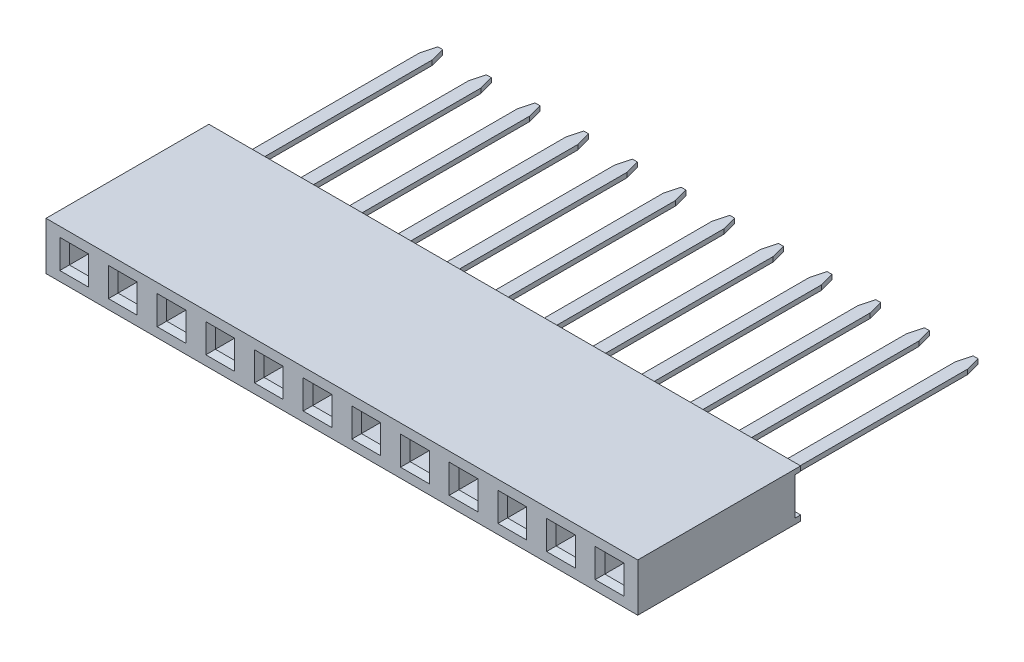
from build123d import *

# Parameters (mm, degrees)
SKETCH1_W                  = 30.88
SKETCH1_H                  = 2.5
BOSS_EXTRUDE1_DEPTH        = 8.5
SKETCH2_W                  = 1
SKETCH2_H                  = 1
CUT_EXTRUDE1_DEPTH         = 2.25
CHAMFER1_SIZE              = 0.25
SKETCH3_W                  = 0.3
SKETCH3_H                  = 1.963850618
CUT_EXTRUDE2_DEPTH         = 31.88
SKETCH4_W                  = 0.65
SKETCH4_H                  = 10.9
BOSS_EXTRUDE2_DEPTH        = 0.125
CHAMFER2_SIZE              = 0.2
CHAMFER2_SIZE2             = 0.746410162
LPATTERN4_COUNT            = 12
LPATTERN4_PITCH            = 2.54
LPATTERN5_COUNT            = 12
LPATTERN5_PITCH            = 2.54
CHAMFER1_OF_LPATTERN5_SIZE = 0.25


with BuildPart() as part:
    # Sketch1 → Boss-Extrude1 (new body)
    with BuildSketch(Plane.XY):
        with Locations((15.44, 1.25)):
            Rectangle(SKETCH1_W, SKETCH1_H)
    extrude(amount=BOSS_EXTRUDE1_DEPTH)

    # Sketch2 → Cut-Extrude1 (cut)
    with BuildSketch(Plane.XY.offset(8.5)):
        with Locations((1.47, 1.25)):
            Rectangle(SKETCH2_W, SKETCH2_H)
    cut_extrude1 = extrude(amount=-CUT_EXTRUDE1_DEPTH, mode=Mode.SUBTRACT)

    # Chamfer1
    chamfer1_edges = [part.edges().sort_by_distance(p)[0] for p in [
        (0.97, 1.25, 8.5),
        (1.47, 0.75, 8.5),
        (1.97, 1.25, 8.5),
        (1.47, 1.75, 8.5),
    ]]
    chamfer(chamfer1_edges, length=CHAMFER1_SIZE)

    # Sketch3 → Cut-Extrude2 (cut, through all)
    with BuildSketch(Plane.ZY):
        with Locations((0.15, 1.268074691)):
            Rectangle(SKETCH3_W, SKETCH3_H)
    extrude(amount=-CUT_EXTRUDE2_DEPTH, mode=Mode.SUBTRACT)

    # LPattern5: Cut-Extrude1 ×12
    with Locations(*[(i * LPATTERN5_PITCH, 0, 0) for i in range(1, LPATTERN5_COUNT)]):
        add(cut_extrude1, mode=Mode.SUBTRACT)

    # Chamfer1 of LPattern5
    chamfer1_of_lpattern5_edges = [part.edges().sort_by_distance(p)[0] for p in [
        (3.51, 1.25, 8.5),
        (4.01, 0.75, 8.5),
        (4.51, 1.25, 8.5),
        (4.01, 1.75, 8.5),
        (6.05, 1.25, 8.5),
        (6.55, 0.75, 8.5),
        (7.05, 1.25, 8.5),
        (6.55, 1.75, 8.5),
        (8.59, 1.25, 8.5),
        (9.09, 0.75, 8.5),
        (9.59, 1.25, 8.5),
        (9.09, 1.75, 8.5),
        (11.13, 1.25, 8.5),
        (11.63, 0.75, 8.5),
        (12.13, 1.25, 8.5),
        (11.63, 1.75, 8.5),
        (13.67, 1.25, 8.5),
        (14.17, 0.75, 8.5),
        (14.67, 1.25, 8.5),
        (14.17, 1.75, 8.5),
        (16.21, 1.25, 8.5),
        (16.71, 0.75, 8.5),
        (17.21, 1.25, 8.5),
        (16.71, 1.75, 8.5),
        (18.75, 1.25, 8.5),
        (19.25, 0.75, 8.5),
        (19.75, 1.25, 8.5),
        (19.25, 1.75, 8.5),
        (21.29, 1.25, 8.5),
        (21.79, 0.75, 8.5),
        (22.29, 1.25, 8.5),
        (21.79, 1.75, 8.5),
        (23.83, 1.25, 8.5),
        (24.33, 0.75, 8.5),
        (24.83, 1.25, 8.5),
        (24.33, 1.75, 8.5),
        (26.37, 1.25, 8.5),
        (26.87, 0.75, 8.5),
        (27.37, 1.25, 8.5),
        (26.87, 1.75, 8.5),
        (28.91, 1.25, 8.5),
        (29.41, 0.75, 8.5),
        (29.91, 1.25, 8.5),
        (29.41, 1.75, 8.5),
    ]]
    chamfer(chamfer1_of_lpattern5_edges, length=CHAMFER1_OF_LPATTERN5_SIZE)


with BuildPart() as body_2:
    # Sketch4 → Boss-Extrude2 (new body, symmetric)
    with BuildSketch(Plane(origin=(0, 1.25, 0), x_dir=(-1, 0, 0), z_dir=(0, -1, 0))):
        with Locations((-1.47, 5.15)):
            Rectangle(SKETCH4_W, SKETCH4_H)
    extrude(amount=BOSS_EXTRUDE2_DEPTH, both=True)

    # Chamfer2
    chamfer2_edges = [body_2.edges().sort_by_distance(p)[0] for p in [
        (1.795, 1.25, -10.6),
        (1.145, 1.25, -10.6),
    ]]
    chamfer2_side = [body_2.faces().sort_by_distance(p)[0] for p in [
        (1.47, 1.25, -10.6),
    ]]
    chamfer(chamfer2_edges, length=CHAMFER2_SIZE, length2=CHAMFER2_SIZE2, reference=chamfer2_side[0])


with BuildPart() as lpattern4_1:
    # LPattern4: pattern copy
    add(body_2.part.moved(Location(Vector(1, 0, 0) * (1 * LPATTERN4_PITCH))))


with BuildPart() as lpattern4_2:
    # LPattern4: pattern copy
    add(body_2.part.moved(Location(Vector(1, 0, 0) * (2 * LPATTERN4_PITCH))))


with BuildPart() as lpattern4_3:
    # LPattern4: pattern copy
    add(body_2.part.moved(Location(Vector(1, 0, 0) * (3 * LPATTERN4_PITCH))))


with BuildPart() as lpattern4_4:
    # LPattern4: pattern copy
    add(body_2.part.moved(Location(Vector(1, 0, 0) * (4 * LPATTERN4_PITCH))))


with BuildPart() as lpattern4_5:
    # LPattern4: pattern copy
    add(body_2.part.moved(Location(Vector(1, 0, 0) * (5 * LPATTERN4_PITCH))))


with BuildPart() as lpattern4_6:
    # LPattern4: pattern copy
    add(body_2.part.moved(Location(Vector(1, 0, 0) * (6 * LPATTERN4_PITCH))))


with BuildPart() as lpattern4_7:
    # LPattern4: pattern copy
    add(body_2.part.moved(Location(Vector(1, 0, 0) * (7 * LPATTERN4_PITCH))))


with BuildPart() as lpattern4_8:
    # LPattern4: pattern copy
    add(body_2.part.moved(Location(Vector(1, 0, 0) * (8 * LPATTERN4_PITCH))))


with BuildPart() as lpattern4_9:
    # LPattern4: pattern copy
    add(body_2.part.moved(Location(Vector(1, 0, 0) * (9 * LPATTERN4_PITCH))))


with BuildPart() as lpattern4_10:
    # LPattern4: pattern copy
    add(body_2.part.moved(Location(Vector(1, 0, 0) * (10 * LPATTERN4_PITCH))))


with BuildPart() as lpattern4_11:
    # LPattern4: pattern copy
    add(body_2.part.moved(Location(Vector(1, 0, 0) * (11 * LPATTERN4_PITCH))))


solid = Compound([part.part, body_2.part, lpattern4_1.part, lpattern4_2.part, lpattern4_3.part, lpattern4_4.part, lpattern4_5.part, lpattern4_6.part, lpattern4_7.part, lpattern4_8.part, lpattern4_9.part, lpattern4_10.part, lpattern4_11.part])
